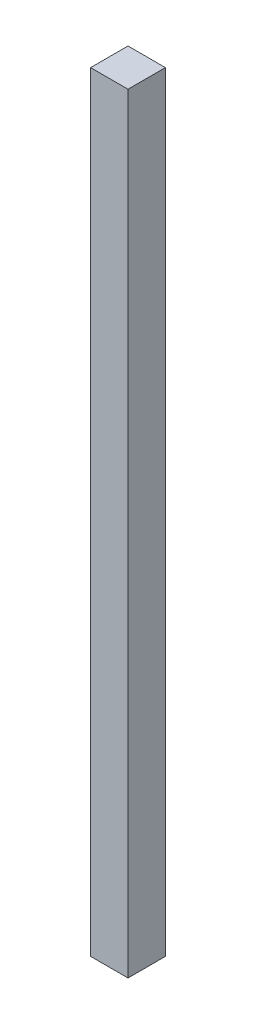
from build123d import *

# Parameters (mm, degrees)
SKETCH1_W           = 88.9
SKETCH1_H           = 88.9
BOSS_EXTRUDE1_DEPTH = 1828.8


with BuildPart() as part:
    # Sketch1 → Boss-Extrude1 (new body)
    with BuildSketch(Plane(origin=(0, 0, 0), x_dir=(1, 0, 0), z_dir=(0, 1, 0))):
        with Locations((-44.45, 44.45)):
            Rectangle(SKETCH1_W, SKETCH1_H)
    extrude(amount=BOSS_EXTRUDE1_DEPTH)


solid = part.part
